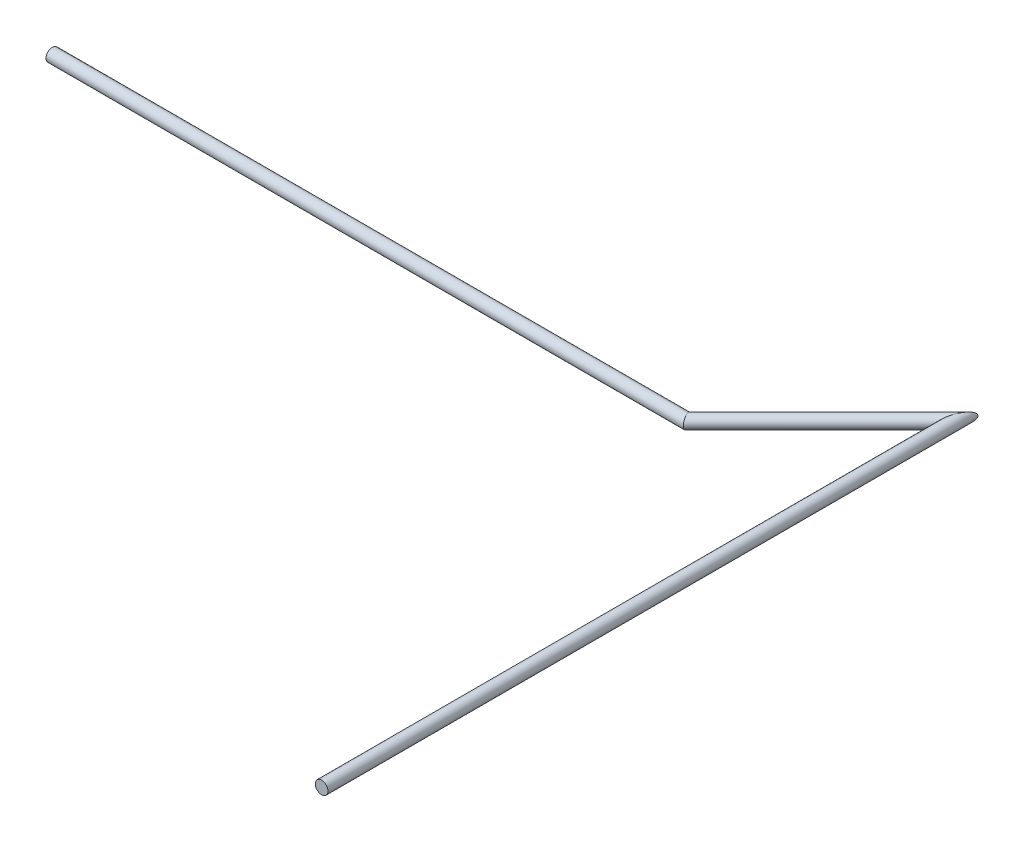
from build123d import *

# Parameters (mm, degrees)
SKETCH1_ON_SEGMENT_1_R                 = 5
ROUND_RODS_ROUND_BAR_10_2_DEPTH        = 503.928932188
SKETCH1_ON_SEGMENT_2_R                 = 5
ROUND_RODS_ROUND_BAR_10_2_2_DEPTH      = 172
SKETCH1_R                              = 5
ROUND_RODS_ROUND_BAR_10_2_3_DEPTH      = 500
ROUND_RODS_ROUND_BAR_10_2_3_DEPTH_BACK = 18.071067812


with BuildPart() as part:
    # Sketch1 on segment 1 (carried to segment 1) → Round-rods ROUND BAR 10(2) (new body)
    with BuildSketch(Plane(origin=(-606.066017178, 0, 106.066017178), x_dir=(0, 0, -1), z_dir=(1, 0, 0))):
        Circle(SKETCH1_ON_SEGMENT_1_R)
    extrude(amount=ROUND_RODS_ROUND_BAR_10_2_DEPTH)

    # Round-rods ROUND BAR 10(2) mitre 1
    split(bisect_by=Plane(origin=(-106.066017178, 0, 106.066017178), x_dir=(0, -1, 0), z_dir=(-0.923879533, 0, 0.382683432)), keep=Keep.TOP)


with BuildPart() as body_2:
    # Sketch1 on segment 2 (carried to segment 2) → Round-rods ROUND BAR 10_2 2 (new body)
    with BuildSketch(Plane(origin=(-108.844191771, 0, 108.844191771), x_dir=(-0.707106781, 0, -0.707106781), z_dir=(0.707106781, 0, -0.707106781))):
        Circle(SKETCH1_ON_SEGMENT_2_R)
    extrude(amount=ROUND_RODS_ROUND_BAR_10_2_2_DEPTH)

    # Round-rods ROUND BAR 10_2 2 mitre 1
    split(bisect_by=Plane(origin=(0, 0, 0), x_dir=(0, -1, 0), z_dir=(-0.923879533, 0, -0.382683432)), keep=Keep.TOP)

    # Round-rods ROUND BAR 10_2 2 mitre 2
    split(bisect_by=Plane(origin=(-106.066017178, 0, 106.066017178), x_dir=(0, 1, 0), z_dir=(0.923879533, 0, -0.382683432)), keep=Keep.TOP)


with BuildPart() as body_3:
    # Sketch1 → Round-rods ROUND BAR 10_2 3 (new, two sides)
    with BuildSketch(Plane.XY) as round_rods_round_bar_10_2_3_sk:
        Circle(SKETCH1_R)
    extrude(amount=ROUND_RODS_ROUND_BAR_10_2_3_DEPTH)
    extrude(round_rods_round_bar_10_2_3_sk.sketch, amount=-ROUND_RODS_ROUND_BAR_10_2_3_DEPTH_BACK)

    # Round-rods ROUND BAR 10_2 3 mitre 1
    split(bisect_by=Plane(origin=(0, 0, 0), x_dir=(0, 1, 0), z_dir=(0.923879533, 0, 0.382683432)), keep=Keep.TOP)


solid = Compound([part.part, body_2.part, body_3.part])
